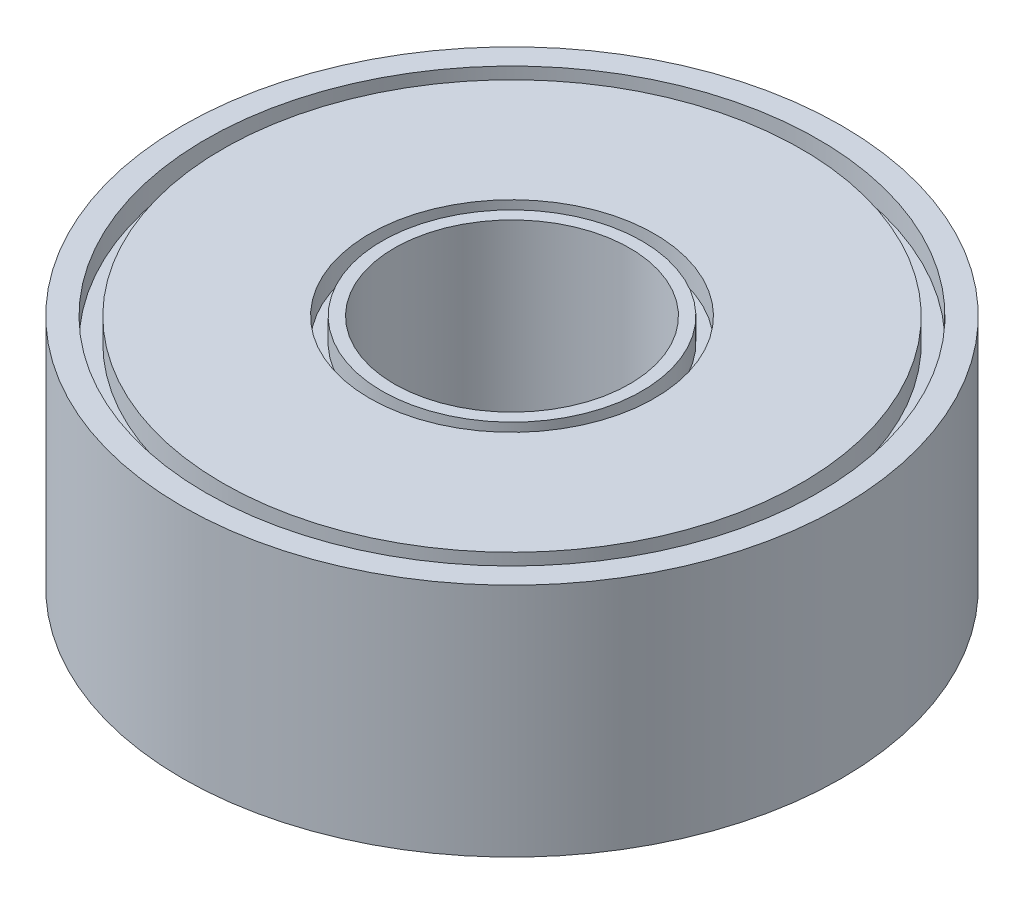
from build123d import *

# Parameters (mm, degrees)
SKETCH1_R           = 7
SKETCH1_R_2         = 2.5
BOSS_EXTRUDE1_DEPTH = 5
SKETCH2_R           = 3.024719142
SKETCH2_R_2         = 2.760237687
CUT_EXTRUDE1_DEPTH  = 0.5
SKETCH3_R           = 6.500951531
SKETCH3_R_2         = 6.143653391
CUT_EXTRUDE2_DEPTH  = 0.5
SKETCH4_R           = 6.653685529
SKETCH4_R_2         = 6.402971613
SKETCH4_R_3         = 3.211895498
SKETCH4_R_4         = 2.91485273
CUT_EXTRUDE3_DEPTH  = 0.5


with BuildPart() as part:
    # Sketch1 → Boss-Extrude1 (new body)
    with BuildSketch(Plane(origin=(0, 0, 0), x_dir=(1, 0, 0), z_dir=(0, 1, 0))):
        with Locations(Location((0, 0, 0), (0, 0, 270))):
            Circle(SKETCH1_R)
        with Locations(Location((0, 0, 0), (0, 0, 270))):
            Circle(SKETCH1_R_2, mode=Mode.SUBTRACT)
    extrude(amount=BOSS_EXTRUDE1_DEPTH)

    # Sketch2 → Cut-Extrude1 (cut)
    with BuildSketch(Plane(origin=(0, 5, 0), x_dir=(1, 0, 0), z_dir=(0, 1, 0))):
        with Locations(Location((0, 0, 0), (0, 0, 270))):
            Circle(SKETCH2_R)
        with Locations(Location((0, 0, 0), (0, 0, 270))):
            Circle(SKETCH2_R_2, mode=Mode.SUBTRACT)
    extrude(amount=-CUT_EXTRUDE1_DEPTH, mode=Mode.SUBTRACT)

    # Sketch3 → Cut-Extrude2 (cut)
    with BuildSketch(Plane(origin=(0, 5, 0), x_dir=(1, 0, 0), z_dir=(0, 1, 0))):
        with Locations(Location((0, 0, 0), (0, 0, 270))):
            Circle(SKETCH3_R)
        with Locations(Location((0, 0, 0), (0, 0, 270))):
            Circle(SKETCH3_R_2, mode=Mode.SUBTRACT)
    extrude(amount=-CUT_EXTRUDE2_DEPTH, mode=Mode.SUBTRACT)

    # Sketch4 → Cut-Extrude3 (cut)
    with BuildSketch(Plane.XZ):
        with Locations(Location((0, 0, 0), (0, 0, 270))):
            Circle(SKETCH4_R)
        with Locations(Location((0, 0, 0), (0, 0, 270))):
            Circle(SKETCH4_R_2, mode=Mode.SUBTRACT)
        with Locations(Location((0, 0, 0), (0, 0, 270))):
            Circle(SKETCH4_R_3)
        with Locations(Location((0, 0, 0), (0, 0, 270))):
            Circle(SKETCH4_R_4, mode=Mode.SUBTRACT)
    extrude(amount=-CUT_EXTRUDE3_DEPTH, mode=Mode.SUBTRACT)


solid = part.part
